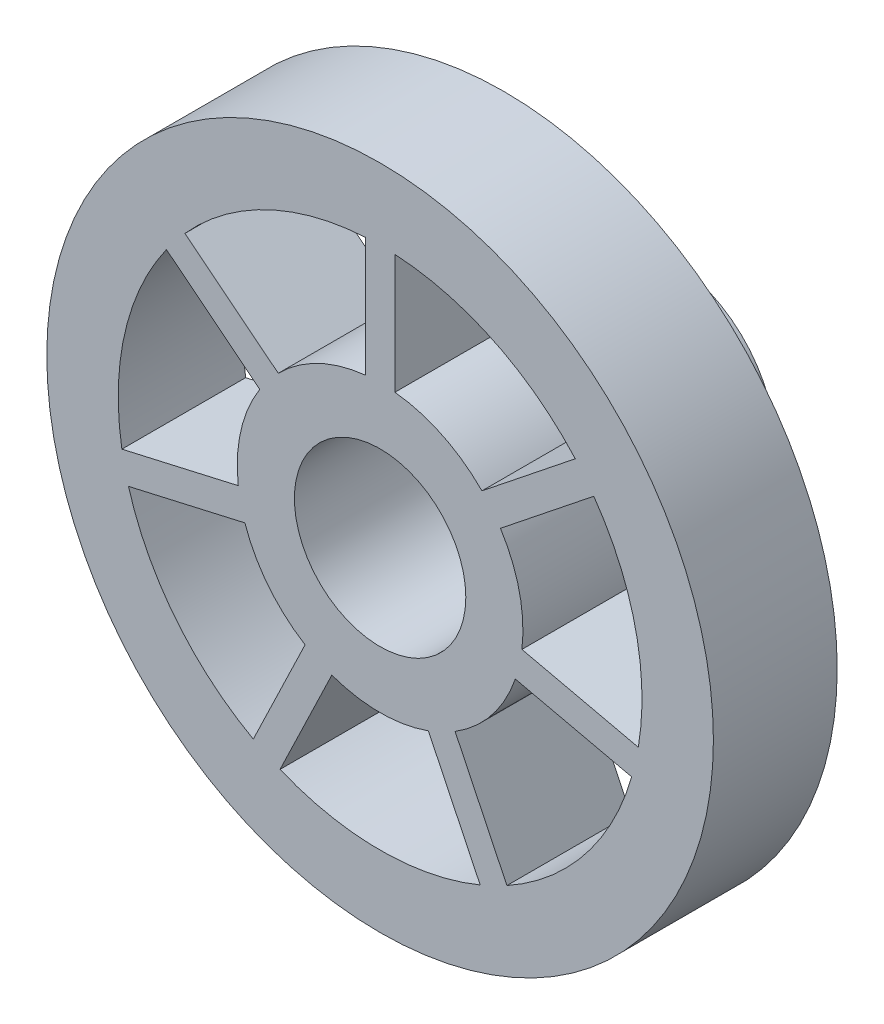
from build123d import *

# Parameters (mm, degrees)
SKETCH1_R                = 11.5
SKETCH1_R_2              = 1.75
BOSS_EXTRUDE2_DEPTH      = 6
SKETCH2_W                = 4
SKETCH2_H                = 2
BOSS_EXTRUDE3_DEPTH      = 12
SKETCH3_R                = 35
SKETCH3_R_2              = 9
BOSS_EXTRUDE5_DEPTH      = 12
BOSS_EXTRUDE5_DEPTH_BACK = 1


with BuildPart() as part:
    # Sketch1 → Boss-Extrude2 (new body)
    with BuildSketch(Plane.XY):
        Circle(SKETCH1_R)
        with Locations((0, 6.5)):
            Circle(SKETCH1_R_2, mode=Mode.SUBTRACT)
        with Locations((6.5, 0)):
            Circle(SKETCH1_R_2, mode=Mode.SUBTRACT)
        with Locations((0, -6.5)):
            Circle(SKETCH1_R_2, mode=Mode.SUBTRACT)
        with Locations((-6.5, 0)):
            Circle(SKETCH1_R_2, mode=Mode.SUBTRACT)
    extrude(amount=BOSS_EXTRUDE2_DEPTH)

    # Sketch2 → Boss-Extrude3 (add)
    with BuildSketch(Plane.XY.offset(6)):
        with Locations((0, 10.324751653)):
            Rectangle(SKETCH2_W, SKETCH2_H)
        with BuildLine():
            Line((-2, 11.324751653), (2, 11.324751653))
            ThreePointArc((2, 11.324751653), (0, 11.5), (-2, 11.324751653))
        make_face()
        with BuildLine():
            ThreePointArc((8.807522623, -7.394426634), (9.959292144, -5.75), (10.807522623, -3.930325019))
            Line((10.807522623, -3.930325019), (8.807522623, -7.394426634))
        make_face()
        Polygon((8.807522623, -7.394426634), (7.075471815, -6.394426634), (9.075471815, -2.930325019), (10.807522623, -3.930325019), align=None)
        with BuildLine():
            ThreePointArc((-10.807522623, -3.930325019), (-9.959292144, -5.75), (-8.807522623, -7.394426634))
            Line((-8.807522623, -7.394426634), (-10.807522623, -3.930325019))
        make_face()
        Polygon((-10.807522623, -3.930325019), (-9.075471815, -2.930325019), (-7.075471815, -6.394426634), (-8.807522623, -7.394426634), align=None)
    extrude(amount=BOSS_EXTRUDE3_DEPTH)

    # Sketch3 → Boss-Extrude5 (add, two sides)
    with BuildSketch(Plane.XY.offset(18)) as boss_extrude5_sk:
        Circle(SKETCH3_R)
        with BuildLine():
            Line((-1.55765655, 27.455850125), (-1.55765655, 14.918904319))
            ThreePointArc((-1.55765655, 14.918904319), (-6.508256087, 13.514533019), (-10.692886106, 10.519609628))
            Line((-10.692886106, 10.519609628), (-20.494665031, 18.336267484))
            ThreePointArc((-20.494665031, 18.336267484), (-11.931802826, 24.776643867), (-1.55765655, 27.455850125))
        make_face(mode=Mode.SUBTRACT)
        with BuildLine():
            Line((-22.437030979, 15.900617624), (-12.635252054, 8.083959768))
            ThreePointArc((-12.635252054, 8.083959768), (-14.623918683, 3.337814009), (-14.89146743, -1.801165674))
            Line((-14.89146743, -1.801165674), (-27.11408583, -4.590898564))
            ThreePointArc((-27.11408583, -4.590898564), (-26.810517585, 6.119325684), (-22.437030979, 15.900617624))
        make_face(mode=Mode.SUBTRACT)
        with BuildLine():
            Line((-26.420863449, -7.628104261), (-14.198245049, -4.838371371))
            ThreePointArc((-14.198245049, -4.838371371), (-11.727472237, -9.352347028), (-7.876470048, -12.765626486))
            Line((-7.876470048, -12.765626486), (-13.316046972, -24.061024356))
            ThreePointArc((-13.316046972, -24.061024356), (-21.500365768, -17.145969551), (-26.420863449, -7.628104261))
        make_face(mode=Mode.SUBTRACT)
        with BuildLine():
            Line((-10.509246854, -25.412708052), (-5.069669931, -14.117310183))
            ThreePointArc((-5.069669931, -14.117310183), (0, -15), (5.069669931, -14.117310183))
            Line((5.069669931, -14.117310183), (10.509246854, -25.412708052))
            ThreePointArc((10.509246854, -25.412708052), (0, -27.5), (-10.509246854, -25.412708052))
        make_face(mode=Mode.SUBTRACT)
        with BuildLine():
            Line((13.316046972, -24.061024356), (7.876470048, -12.765626486))
            ThreePointArc((7.876470048, -12.765626486), (11.727472237, -9.352347028), (14.198245049, -4.838371371))
            Line((14.198245049, -4.838371371), (26.420863449, -7.628104261))
            ThreePointArc((26.420863449, -7.628104261), (21.500365768, -17.145969551), (13.316046972, -24.061024356))
        make_face(mode=Mode.SUBTRACT)
        with BuildLine():
            Line((27.11408583, -4.590898564), (14.89146743, -1.801165674))
            ThreePointArc((14.89146743, -1.801165674), (14.623918683, 3.337814009), (12.635252054, 8.083959768))
            Line((12.635252054, 8.083959768), (22.437030979, 15.900617624))
            ThreePointArc((22.437030979, 15.900617624), (26.810517585, 6.119325684), (27.11408583, -4.590898564))
        make_face(mode=Mode.SUBTRACT)
        with BuildLine():
            Line((20.494665031, 18.336267484), (10.692886106, 10.519609628))
            ThreePointArc((10.692886106, 10.519609628), (6.508256087, 13.514533019), (1.55765655, 14.918904319))
            Line((1.55765655, 14.918904319), (1.55765655, 27.455850125))
            ThreePointArc((1.55765655, 27.455850125), (11.931802826, 24.776643867), (20.494665031, 18.336267484))
        make_face(mode=Mode.SUBTRACT)
        Circle(SKETCH3_R_2, mode=Mode.SUBTRACT)
    extrude(amount=BOSS_EXTRUDE5_DEPTH)
    extrude(boss_extrude5_sk.sketch, amount=-BOSS_EXTRUDE5_DEPTH_BACK)


solid = part.part
